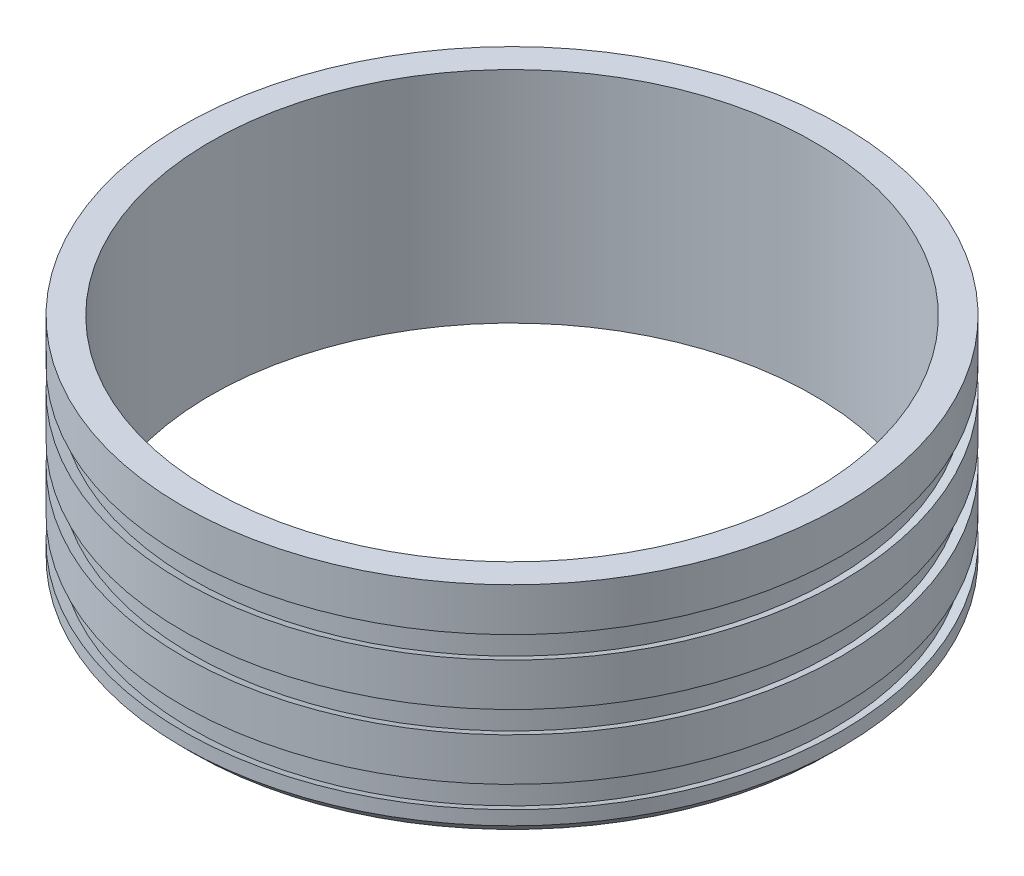
from build123d import *

# Parameters (mm, degrees)
SKETCH1_R           = 76.25
SKETCH1_R_2         = 69.75
BOSS_EXTRUDE1_DEPTH = 50.8
CHAMFER1_SIZE       = 2.5


with BuildPart() as part:
    # Sketch1 → Boss-Extrude1 (new body)
    with BuildSketch(Plane(origin=(0, 0, 0), x_dir=(1, 0, 0), z_dir=(0, 1, 0))):
        Circle(SKETCH1_R)
        Circle(SKETCH1_R_2, mode=Mode.SUBTRACT)
    extrude(amount=BOSS_EXTRUDE1_DEPTH)

    # Sketch2 → Cut-Revolve1 (revolve, cut)
    with BuildSketch(Plane.XY):
        Polygon((-76.25, 40.8), (-76.25, 35.72), (-74, 34.901066973), (-74, 41.618933027), align=None)
        Polygon((-74, 26.618933027), (-74, 19.901066973), (-76.25, 20.72), (-76.25, 25.8), align=None)
        Polygon((-74, 11.618933027), (-74, 4.901066973), (-76.25, 5.72), (-76.25, 10.8), align=None)
    revolve(axis=Axis((0, 0, 0), (0, 1, 0)), mode=Mode.SUBTRACT)

    # Chamfer1
    chamfer1_edges = [part.edges().sort_by_distance(p)[0] for p in [
        (-76.25, 0, 0),
    ]]
    chamfer(chamfer1_edges, length=CHAMFER1_SIZE)


solid = part.part
